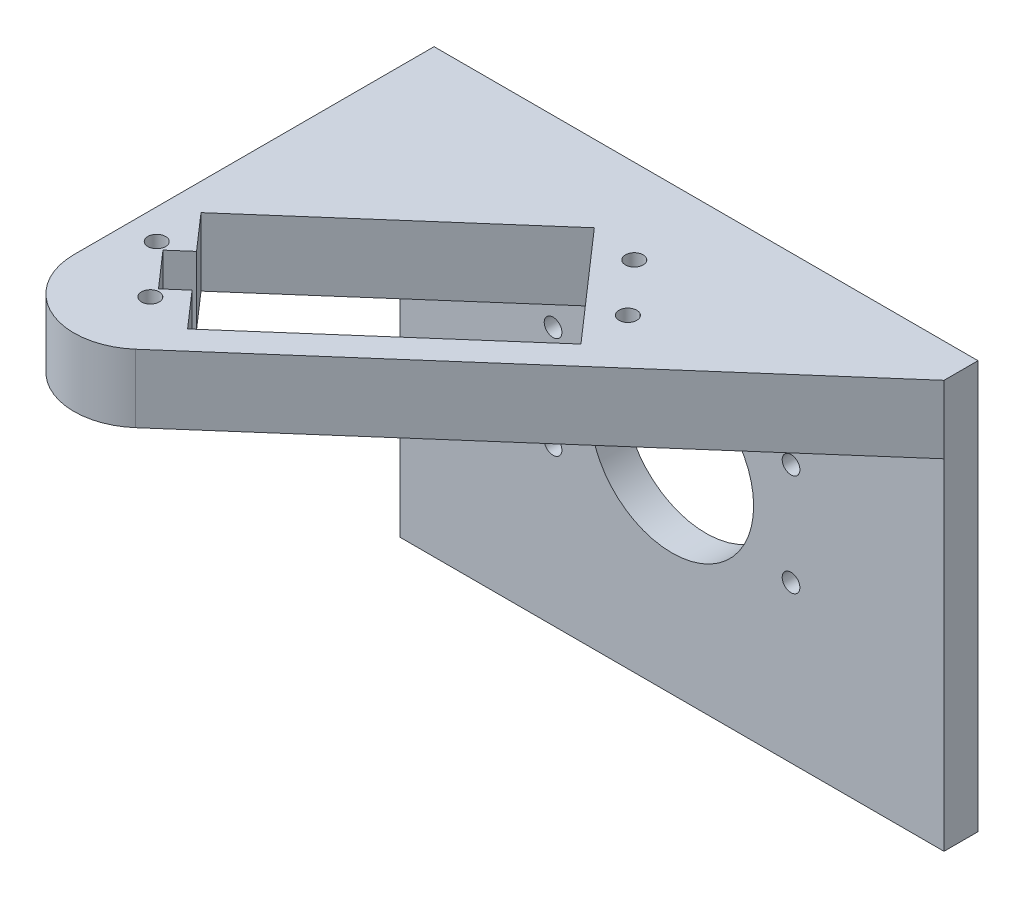
from build123d import *

# Parameters (mm, degrees)
SZKIC1_W                    = 80
SZKIC1_H                    = 60
DODANIE_WYCI_GNI_CIE1_DEPTH = 5
DODANIE_WYCI_GNI_CIE2_DEPTH = 10
OTW_R_POD_RUB_M22_D         = 2.6
OTW_R_POD_RUB_M22_DEPTH     = 5
WYTNIJ_WYCI_GNI_CIE2_REACH  = 12
OTW_R_POD_RUB_M21_D         = 2.6
OTW_R_POD_RUB_M21_DEPTH     = 10
ZAOKR_GLENIE5_R             = 10
OTW_R_POD_RUB_M201_D        = 24
OTW_R_POD_RUB_M201_DEPTH    = 5


with BuildPart() as part:
    # Szkic1 → Dodanie-wyciągnięcie1 (new body)
    with BuildSketch(Plane.XY):
        Rectangle(SZKIC1_W, SZKIC1_H)
    extrude(amount=DODANIE_WYCI_GNI_CIE1_DEPTH)

    # Szkic2 → Dodanie-wyciągnięcie2 (add)
    with BuildSketch(Plane(origin=(0, 30, 0), x_dir=(1, 0, 0), z_dir=(0, 1, 0))):
        Polygon((40, 0), (-40, 0), (-40, -75), (40, -5), align=None)
    extrude(amount=-DODANIE_WYCI_GNI_CIE2_DEPTH)

    # Otwór pod śrubę M22
    with Locations(Plane(origin=(-17.5, 8, 5), x_dir=(1, 0, 0), z_dir=(0, 0, 1))):
        with Locations((0, 0), (0, -15), (35, 0), (35, -15)):
            Hole(OTW_R_POD_RUB_M22_D / 2, depth=OTW_R_POD_RUB_M22_DEPTH)

    # Szkic17 → Wytnij-wyciągnięcie2 (cut, up to next)
    with BuildSketch(Plane.XZ.offset(-20), mode=Mode.PRIVATE) as wytnij_wyci_gni_cie2_sk1:
        Polygon((-36, 38.280794335), (-5.144355517, 11.282105413), (8.684241248, 27.086216001), (-22.171403235, 54.084904924), (-26.78093549, 48.816868061), (-29.414953921, 51.121634189), (-34.024486176, 45.853597326), (-31.390467745, 43.548831198), align=None)
    wytnij_wyci_gni_cie2_tool1 = extrude(wytnij_wyci_gni_cie2_sk1.sketch, amount=-WYTNIJ_WYCI_GNI_CIE2_REACH, mode=Mode.PRIVATE) & part.part
    add(wytnij_wyci_gni_cie2_tool1.solids().sort_by_distance((-14.121175, 20, 33.088889))[0], mode=Mode.SUBTRACT)

    # Otwór pod śrubę M21
    with Locations(Plane(origin=(0, 20, 0), x_dir=(-1, 0, 0), z_dir=(0, -1, 0))):
        with Locations((35.576675609, -45.21861074), (28.991629531, -52.744377687), (-8.471638332, -19.964018307), (-1.886592253, -12.43825136)):
            Hole(OTW_R_POD_RUB_M21_D / 2, depth=OTW_R_POD_RUB_M21_DEPTH)

    # Zaokrąglenie5
    zaokr_glenie5_edges = [part.edges().sort_by_distance(p)[0] for p in [
        (-40, 25, 75),
    ]]
    fillet(zaokr_glenie5_edges, radius=ZAOKR_GLENIE5_R)

    # Otwór pod śrubę M201
    with Locations(Plane(origin=(0, 0, 0), x_dir=(-1, 0, 0), z_dir=(0, 0, -1))):
        with Locations((0, 0)):
            Hole(OTW_R_POD_RUB_M201_D / 2, depth=OTW_R_POD_RUB_M201_DEPTH)


solid = part.part
